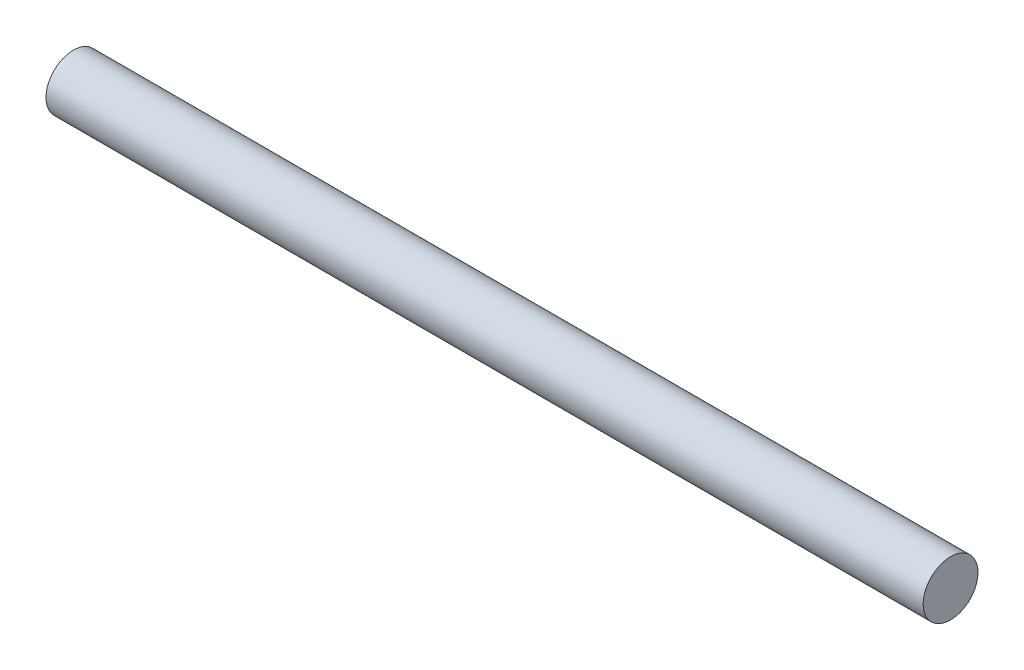
from build123d import *

# Parameters (mm, degrees)
SKETCH1_R           = 2.38125
BOSS_EXTRUDE1_DEPTH = 76.2


with BuildPart() as part:
    # Sketch1 → Boss-Extrude1 (new body)
    with BuildSketch(Plane(origin=(0, 0, 0), x_dir=(0, 0, -1), z_dir=(1, 0, 0))):
        Circle(SKETCH1_R)
    extrude(amount=BOSS_EXTRUDE1_DEPTH)


solid = part.part
